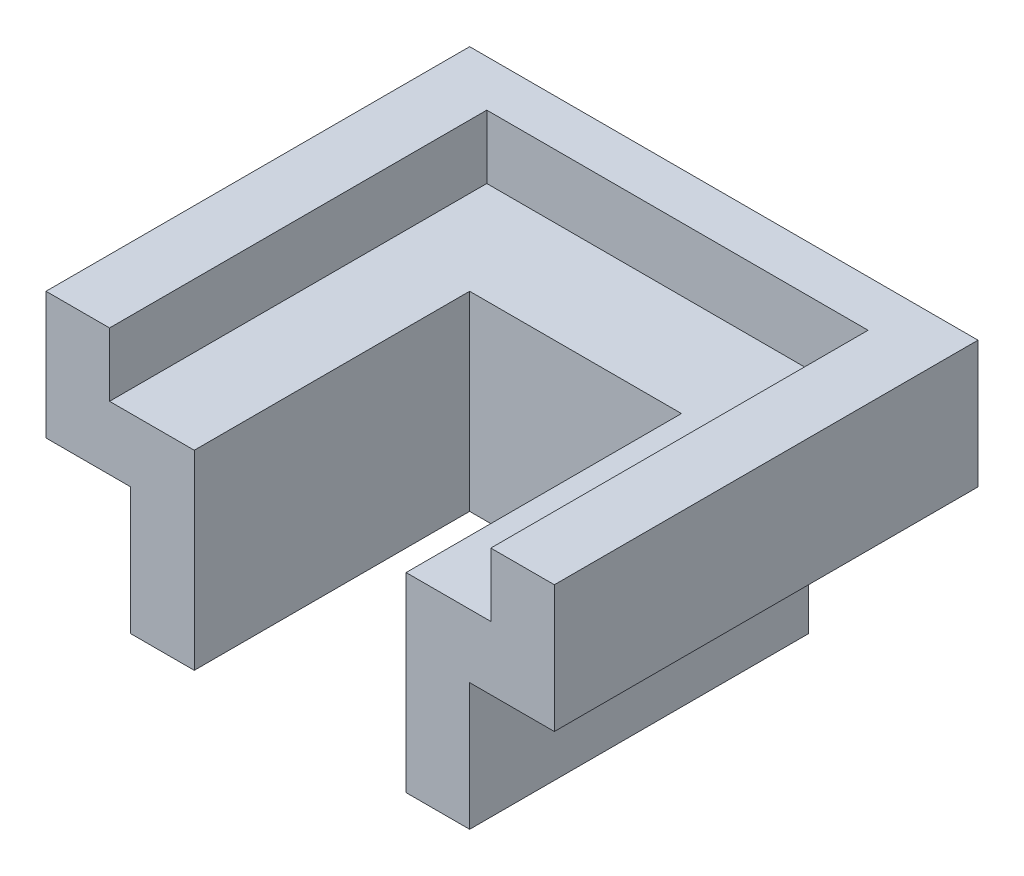
from build123d import *

# Parameters (mm, degrees)
SKETCH1_W           = 63.5
SKETCH1_H           = 19.05
BOSS_EXTRUDE1_DEPTH = 38.1
SKETCH2_W           = 57.15
SKETCH2_H           = 56.546509541
CUT_EXTRUDE1_DEPTH  = 9.525
BOSS_EXTRUDE3_DEPTH = 19.05
SKETCH6_W           = 31.75
SKETCH6_H           = 41.275
CUT_EXTRUDE3_DEPTH  = 19.05


with BuildPart() as part:
    # Sketch1 → Boss-Extrude1 (new body, symmetric)
    with BuildSketch(Plane(origin=(0, 0, 0), x_dir=(0, 0, -1), z_dir=(1, 0, 0))):
        with Locations((19.525170068, 1.123129252)):
            Rectangle(SKETCH1_W, SKETCH1_H)
    extrude(amount=BOSS_EXTRUDE1_DEPTH, both=True)

    # Sketch2 → Cut-Extrude1 (cut)
    with BuildSketch(Plane(origin=(0, 10.648129252, 0), x_dir=(1, 0, 0), z_dir=(0, 1, 0))):
        with Locations((0, 16.048424839)):
            Rectangle(SKETCH2_W, SKETCH2_H)
    extrude(amount=-CUT_EXTRUDE1_DEPTH, mode=Mode.SUBTRACT)

    # Sketch5 → Boss-Extrude3 (add)
    with BuildSketch(Plane.XZ.offset(8.401870748)):
        Polygon((-25.4, 12.224829932), (-15.875, 12.224829932), (-15.875, -29.050170068), (15.875, -29.050170068), (15.875, 12.224829932), (25.4, 12.224829932), (25.4, -38.575170068), (-25.4, -38.575170068), align=None)
    extrude(amount=BOSS_EXTRUDE3_DEPTH)

    # Sketch6 → Cut-Extrude3 (cut)
    with BuildSketch(Plane.XZ.offset(8.401870748)):
        with Locations((0, -8.412670068)):
            Rectangle(SKETCH6_W, SKETCH6_H)
    extrude(amount=-CUT_EXTRUDE3_DEPTH, mode=Mode.SUBTRACT)


solid = part.part
